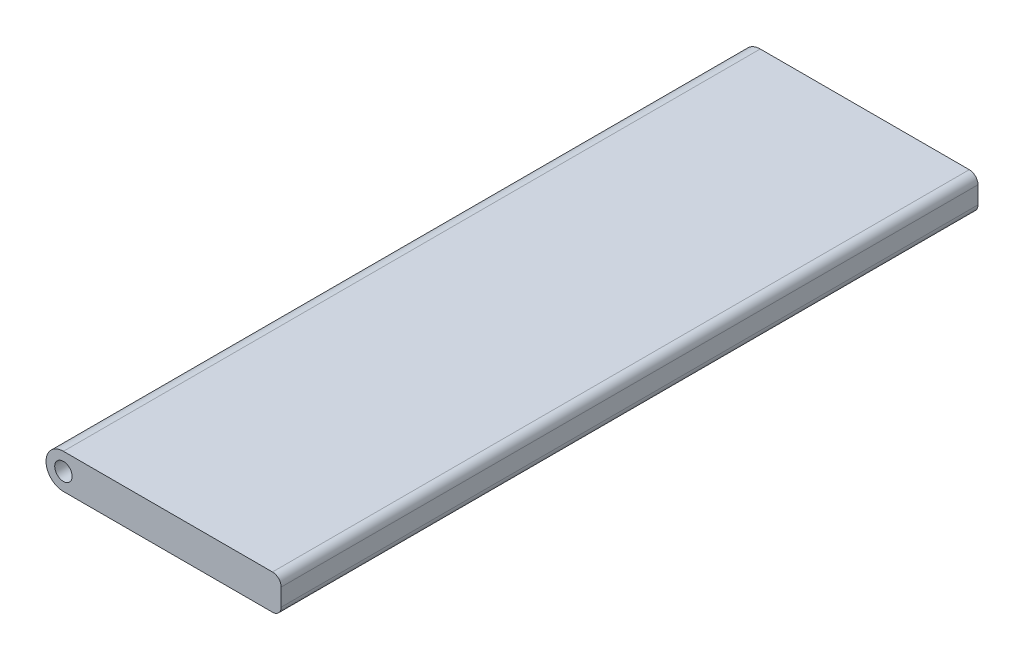
from build123d import *

# Parameters (mm, degrees)
EXTRUDE_1_DEPTH = 80


with BuildPart() as part:
    # 草图1 → 凸台-拉伸1 (new body)
    with BuildSketch(Plane.XY):
        with BuildLine():
            ThreePointArc((0, 2), (-2, 0), (0, -2))
            Line((0, -2), (0, -1))
            ThreePointArc((0, -1), (-1, 0), (0, 1))
            Line((0, 1), (0, 2))
        make_face()
        with BuildLine():
            Line((0, -1), (0, -2))
            ThreePointArc((0, -2), (1.414213562, -1.414213562), (2, 0))
            ThreePointArc((2, 0), (1.414213562, 1.414213562), (0, 2))
            Line((0, 2), (0, 1))
            ThreePointArc((0, 1), (0.707106781, 0.707106781), (1, 0))
            ThreePointArc((1, 0), (0.707106781, -0.707106781), (0, -1))
        make_face()
        with BuildLine():
            ThreePointArc((2, 0), (1.414213562, -1.414213562), (0, -2))
            Line((0, -2), (24, -2))
            ThreePointArc((24, -2), (24.707106781, -1.707106781), (25, -1))
            Line((25, -1), (25, 1))
            ThreePointArc((25, 1), (24.707106781, 1.707106781), (24, 2))
            Line((24, 2), (0, 2))
            ThreePointArc((0, 2), (1.414213562, 1.414213562), (2, 0))
        make_face()
    extrude(amount=EXTRUDE_1_DEPTH)


solid = part.part
